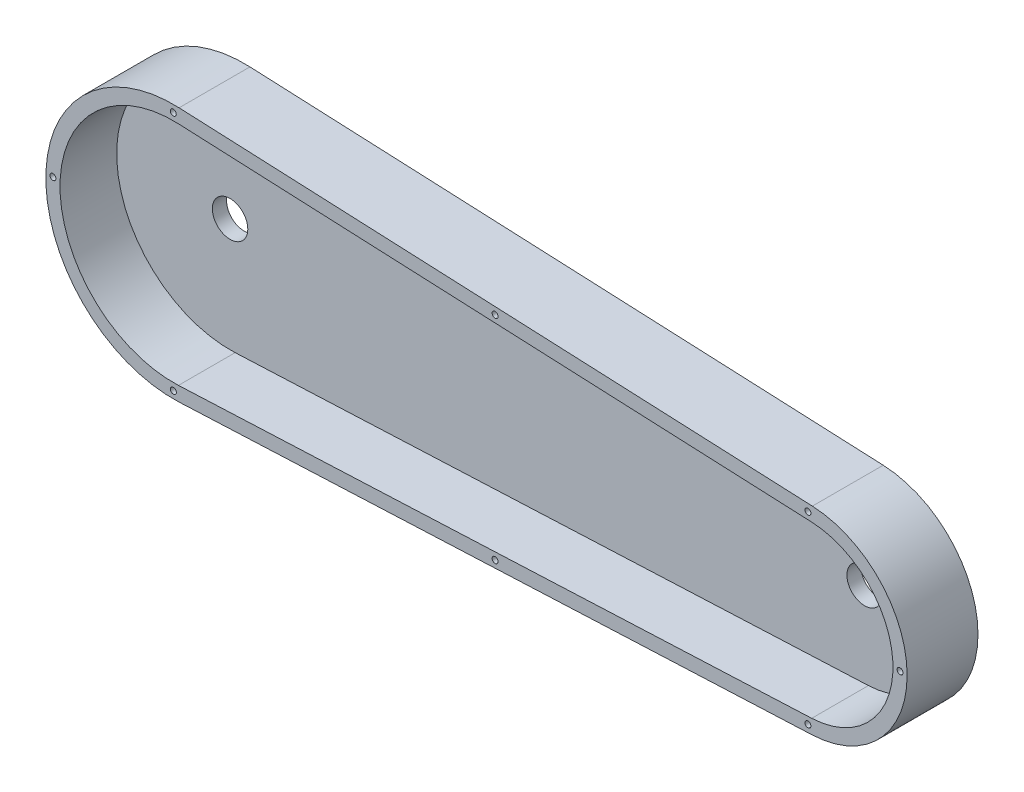
from build123d import *

# Parameters (mm, degrees)
BOSS_EXTRUDE2_DEPTH   = 50
SHELL2_T              = -10
SKETCH2_R             = 12.5
CUT_EXTRUDE1_DEPTH    = 10
M5_TAPPED_HOLE1_D     = 4.2
M5_TAPPED_HOLE1_DEPTH = 10
M5_TAPPED_HOLE1_TIP   = 1.2618073
SKETCH7_R             = 2.5
BOSS_EXTRUDE3_DEPTH   = 20


with BuildPart() as part:
    # Sketch1 → Boss-Extrude2 (new body)
    with BuildSketch(Plane.XY):
        with BuildLine():
            Line((-71.001256012, 89.910155998), (375.818743988, 69.930121332))
            ThreePointArc((375.818743988, 69.930121332), (442.691743746, 0), (375.818743988, -69.930121332))
            Line((375.818743988, -69.930121332), (-71.001256012, -89.910155998))
            ThreePointArc((-71.001256012, -89.910155998), (-165.021684895, 0), (-71.001256012, 89.910155998))
        make_face()
    extrude(amount=BOSS_EXTRUDE2_DEPTH)

    # Shell2
    shell2_openings = [part.faces().sort_by_distance(p)[0] for p in [
        (145.621886707, 0, 50),
    ]]
    offset(amount=SHELL2_T, openings=shell2_openings, kind=Kind.INTERSECTION)

    # Sketch2 → Cut-Extrude1 (cut)
    with BuildSketch(Plane.XY.offset(10)):
        with Locations((-75.021684895, 0)):
            Circle(SKETCH2_R)
        with Locations((372.691743746, 0)):
            Circle(SKETCH2_R)
    extrude(amount=-CUT_EXTRUDE1_DEPTH, mode=Mode.SUBTRACT)

    # M5 Tapped Hole1
    with Locations(Plane.XY.offset(50)):
        with Locations((-160.021684895, 3.133929532), (-75.081342532, 85), (-75.021684895, -85), (437.691743746, 0), (372.686127316, -64.999999757), (372.691743746, 65), (151.962029668, 74.920138665), (151.962918886, -74.94005433)):
            Hole(M5_TAPPED_HOLE1_D / 2, depth=M5_TAPPED_HOLE1_DEPTH)
            with Locations((0, 0, -(M5_TAPPED_HOLE1_DEPTH + M5_TAPPED_HOLE1_TIP / 2))):  # 118° drill point
                Cone(0, M5_TAPPED_HOLE1_D / 2, M5_TAPPED_HOLE1_TIP, mode=Mode.SUBTRACT)

    # Sketch7 → Boss-Extrude3 (add)
    with BuildSketch(Plane(origin=(0, 0, 0), x_dir=(-1, 0, 0), z_dir=(0, 0, -1))):
        Polygon((-268.221462492, -5.800860149), (-109.826947867, -27.830102859), (-93.540881228, -30.095141618), (-90.785832397, -10.285807809), (-288.879170482, 17.264680503), (-291.634219314, -2.544653305), align=None)
        with Locations((-270.447361089, 4.604964768)):
            Circle(SKETCH7_R, mode=Mode.SUBTRACT)
        with Locations((-191.210025855, -6.415230557)):
            Circle(SKETCH7_R, mode=Mode.SUBTRACT)
        with Locations((-111.972690621, -17.435425882)):
            Circle(SKETCH7_R, mode=Mode.SUBTRACT)
    extrude(amount=BOSS_EXTRUDE3_DEPTH)


solid = part.part
